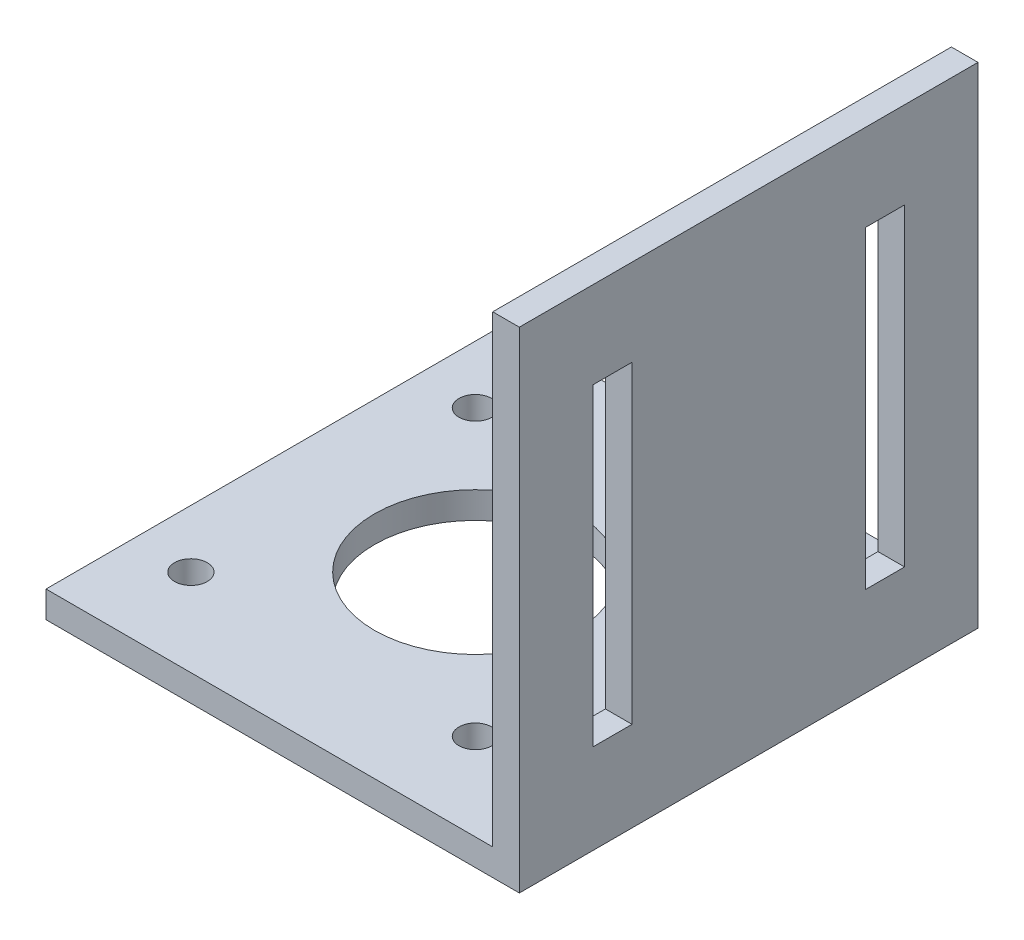
from build123d import *

# Parameters (mm, degrees)
SKETCH1_W           = 51.58
SKETCH1_H           = 49.98
BOSS_EXTRUDE1_DEPTH = 2.9
SKETCH2_W           = 2.9
SKETCH2_H           = 49.98
BOSS_EXTRUDE2_DEPTH = 50.5
SKETCH4_W           = 4.28
SKETCH4_H           = 34.17
CUT_EXTRUDE1_DEPTH  = 52.58
SKETCH5_R           = 11
SKETCH5_R_2         = 1.785
CUT_EXTRUDE2_DEPTH  = 54.4


with BuildPart() as part:
    # Sketch1 → Boss-Extrude1 (new body)
    with BuildSketch(Plane(origin=(0, 0, 0), x_dir=(1, 0, 0), z_dir=(0, 1, 0))):
        with Locations((25.79, 24.99)):
            Rectangle(SKETCH1_W, SKETCH1_H)
    extrude(amount=BOSS_EXTRUDE1_DEPTH)

    # Sketch2 → Boss-Extrude2 (add)
    with BuildSketch(Plane(origin=(0, 2.9, 0), x_dir=(1, 0, 0), z_dir=(0, 1, 0))):
        with Locations((50.13, 24.99)):
            Rectangle(SKETCH2_W, SKETCH2_H)
    extrude(amount=BOSS_EXTRUDE2_DEPTH)

    # Sketch4 → Cut-Extrude1 (cut, through all)
    with BuildSketch(Plane(origin=(51.58, 0, 0), x_dir=(0, 0, -1), z_dir=(1, 0, 0))):
        with Locations((10.14, 26.865)):
            Rectangle(SKETCH4_W, SKETCH4_H)
        with Locations((39.84, 26.865)):
            Rectangle(SKETCH4_W, SKETCH4_H)
    extrude(amount=-CUT_EXTRUDE1_DEPTH, mode=Mode.SUBTRACT)

    # Sketch5 → Cut-Extrude2 (cut, through all)
    with BuildSketch(Plane.XZ):
        with Locations((21.8, -24.99)):
            Circle(SKETCH5_R)
        with Locations((6.3, -40.49)):
            Circle(SKETCH5_R_2)
        with Locations((37.3, -40.49)):
            Circle(SKETCH5_R_2)
        with Locations((37.3, -9.49)):
            Circle(SKETCH5_R_2)
        with Locations((6.3, -9.49)):
            Circle(SKETCH5_R_2)
    extrude(amount=-CUT_EXTRUDE2_DEPTH, mode=Mode.SUBTRACT)


solid = part.part
